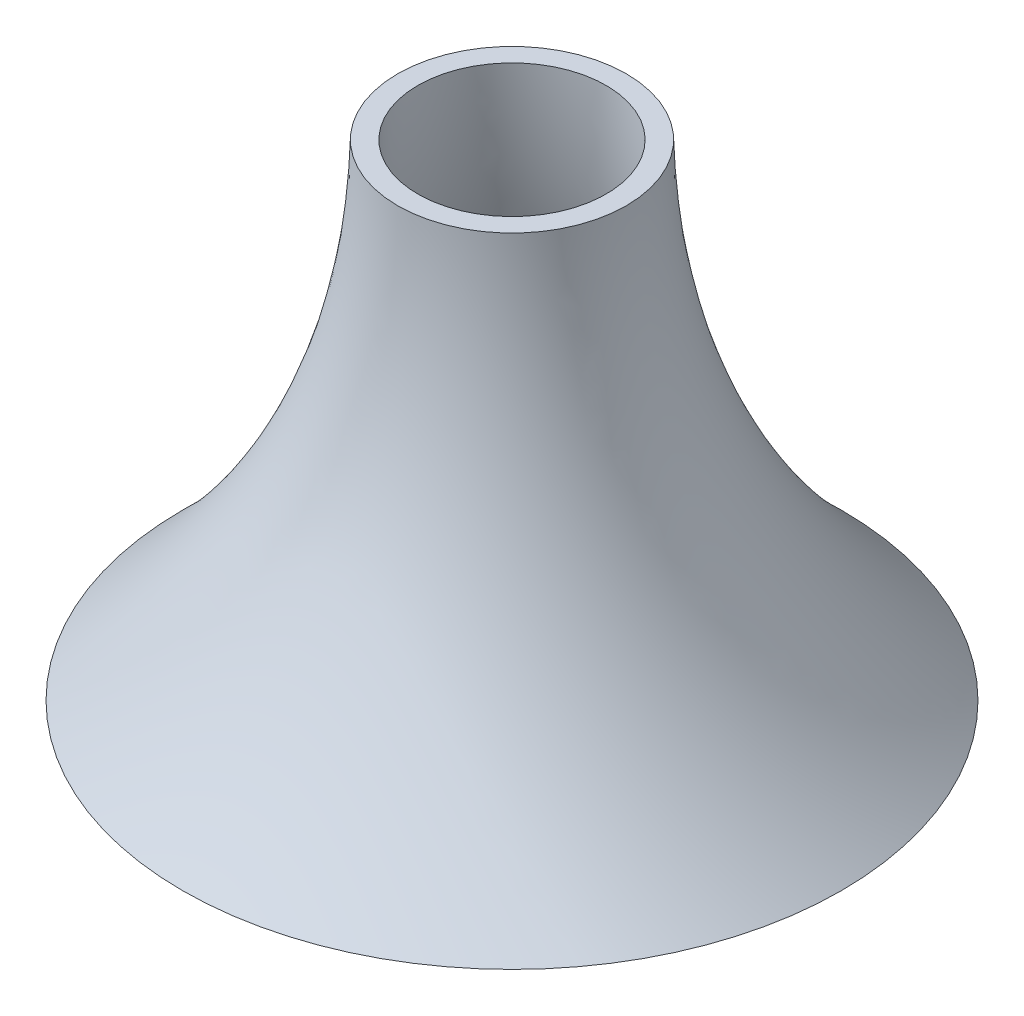
from build123d import *


with BuildPart() as part:
    # Sketch2 → Revolve1 (revolve)
    with BuildSketch(Plane.XY):
        with BuildLine():
            Line((35, 98.40394622), (42.5, 98.40394622))
            add(Edge.make_bspline(
                [(42.5, 98.40394622), (45.083395915, -8.43095742), (122.498890748, -82.101154559)],
                knots=[0, 0, 0, 1, 1, 1], degree=2))
            Line((122.498890748, -82.101154559), (114.998890748, -82.101154559))
            add(Edge.make_bspline(
                [(35, 98.40394622), (37.583395915, -8.43095742), (114.998890748, -82.101154559)],
                knots=[0, 0, 0, 1, 1, 1], degree=2))
        make_face()
    revolve(axis=Axis((0, 105.448040777, 0), (0, -1, 0)))


solid = part.part
